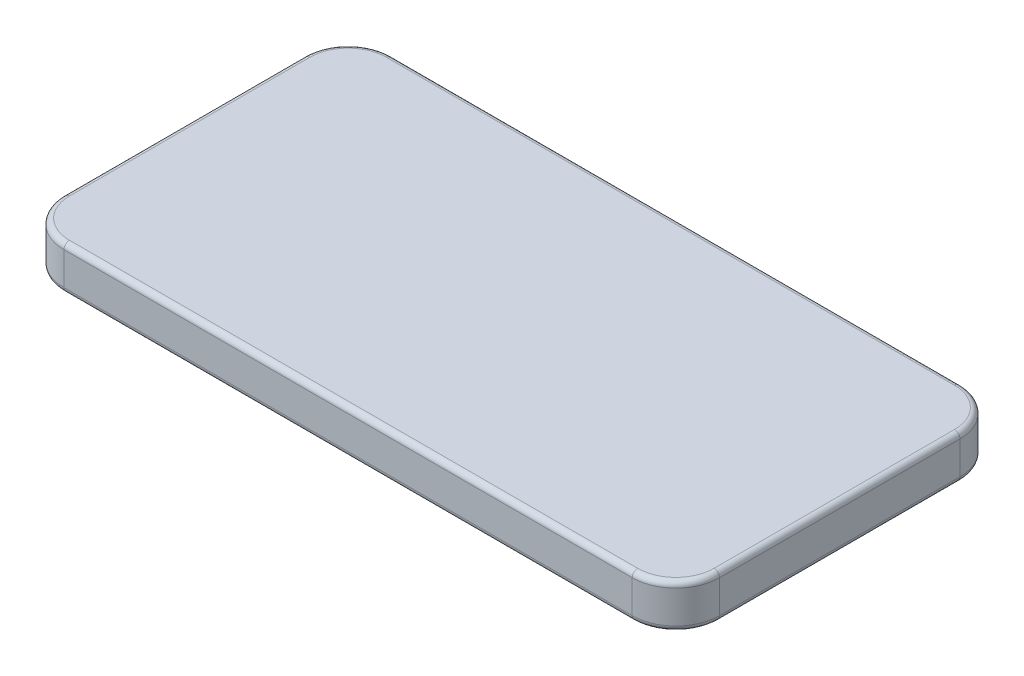
from build123d import *

# Parameters (mm, degrees)
BOSS_EXTRUDE1_DEPTH = 50.8
FILLET1_R           = 6.35
FILLET2_R           = 6.35


with BuildPart() as part:
    # Sketch1 → Boss-Extrude1 (new body)
    with BuildSketch(Plane(origin=(0, 0, 0), x_dir=(1, 0, 0), z_dir=(0, 1, 0))):
        with BuildLine():
            Line((50.8, 0), (711.2, 0))
            ThreePointArc((711.2, 0), (747.121024484, 14.878975516), (762, 50.8))
            Line((762, 50.8), (762, 330.2))
            ThreePointArc((762, 330.2), (747.121024484, 366.121024484), (711.2, 381))
            Line((711.2, 381), (50.8, 381))
            ThreePointArc((50.8, 381), (14.878975516, 366.121024484), (0, 330.2))
            Line((0, 330.2), (0, 50.8))
            ThreePointArc((0, 50.8), (14.878975516, 14.878975516), (50.8, 0))
        make_face()
    extrude(amount=BOSS_EXTRUDE1_DEPTH)

    # Fillet1
    fillet1_edges = [part.edges().sort_by_distance(p)[0] for p in [
        (14.878975516, 50.8, -14.878975516),
        (381, 50.8, 0),
        (747.121024484, 50.8, -14.878975516),
        (762, 50.8, -190.5),
        (747.121024484, 50.8, -366.121024484),
        (381, 50.8, -381),
        (14.878975516, 50.8, -366.121024484),
        (0, 50.8, -190.5),
    ]]
    fillet(fillet1_edges, radius=FILLET1_R)

    # Fillet2
    fillet2_edges = [part.edges().sort_by_distance(p)[0] for p in [
        (0, 0, -190.5),
        (14.878975516, 0, -366.121024484),
        (381, 0, -381),
        (747.121024484, 0, -366.121024484),
        (762, 0, -190.5),
        (747.121024484, 0, -14.878975516),
        (381, 0, 0),
        (14.878975516, 0, -14.878975516),
    ]]
    fillet(fillet2_edges, radius=FILLET2_R)


solid = part.part
